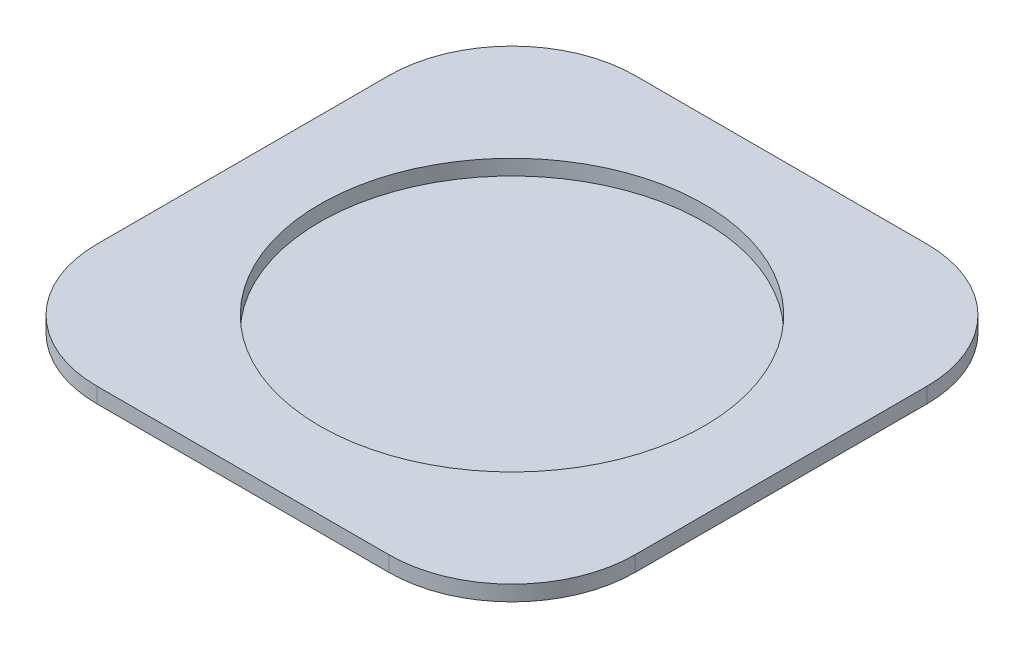
from build123d import *

# Parameters (mm, degrees)
SKETCH1_W           = 70
SKETCH1_H           = 70
SKETCH1_R           = 25
BOSS_EXTRUDE1_DEPTH = 2
FILLET1_R           = 16
SKETCH2_R           = 32.5
BOSS_EXTRUDE2_DEPTH = 2


with BuildPart() as part:
    # Sketch1 → Boss-Extrude1 (new body)
    with BuildSketch(Plane(origin=(0, 0, 0), x_dir=(1, 0, 0), z_dir=(0, 1, 0))):
        Rectangle(SKETCH1_W, SKETCH1_H)
        Circle(SKETCH1_R, mode=Mode.SUBTRACT)
    extrude(amount=BOSS_EXTRUDE1_DEPTH)

    # Fillet1
    fillet1_edges = [part.edges().sort_by_distance(p)[0] for p in [
        (35, 1, 35),
        (-35, 1, 35),
        (-35, 1, -35),
        (35, 1, -35),
    ]]
    fillet(fillet1_edges, radius=FILLET1_R)

    # Sketch2 → Boss-Extrude2 (add)
    with BuildSketch(Plane.XZ):
        Circle(SKETCH2_R)
    extrude(amount=BOSS_EXTRUDE2_DEPTH)


solid = part.part
